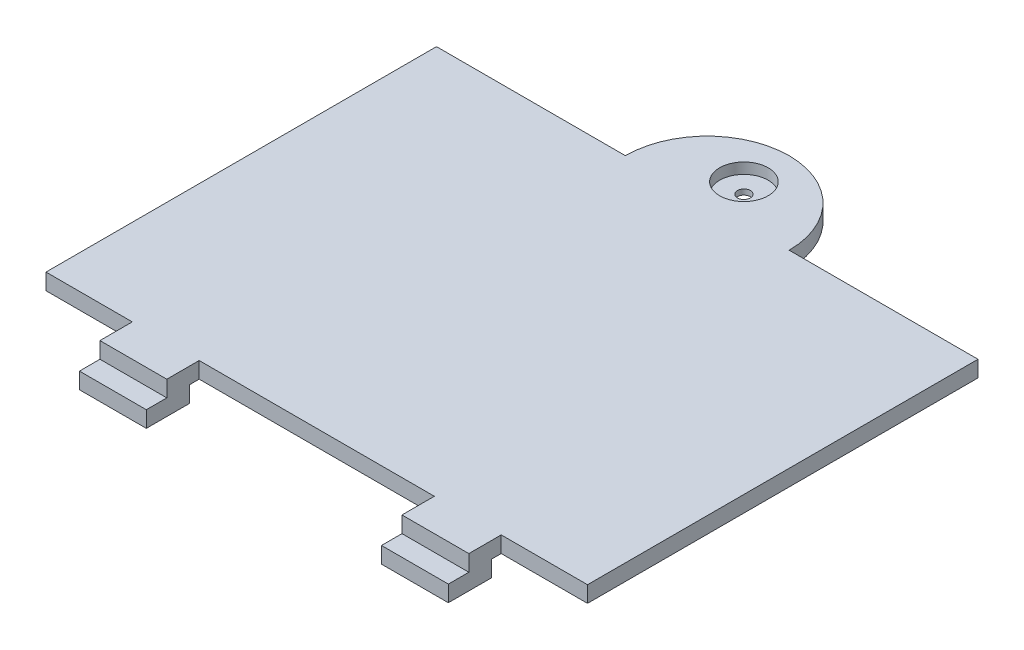
from build123d import *

# Parameters (mm, degrees)
SKETCH1_W           = 50.2
SKETCH1_H           = 36.2
BOSS_EXTRUDE1_DEPTH = 1.5
SKETCH2_W           = 6.2
SKETCH2_H           = 1.5
BOSS_EXTRUDE2_DEPTH = 3
BOSS_EXTRUDE3_DEPTH = 1.5
SKETCH5_R           = 2.25
CUT_EXTRUDE1_DEPTH  = 1
SKETCH6_R           = 0.6
CUT_EXTRUDE2_DEPTH  = 1
SKETCH9_W           = 6.2
SKETCH9_H           = 4
BOSS_EXTRUDE4_DEPTH = 1.5


with BuildPart() as part:
    # Sketch1 → Boss-Extrude1 (new body)
    with BuildSketch(Plane(origin=(0, 0, 0), x_dir=(1, 0, 0), z_dir=(0, 1, 0))):
        with Locations((-25.1, -18.1)):
            Rectangle(SKETCH1_W, SKETCH1_H)
    extrude(amount=BOSS_EXTRUDE1_DEPTH)

    # Sketch2 → Boss-Extrude2 (add)
    with BuildSketch(Plane.XY.offset(36.2)):
        with Locations((-39.1, 0.75)):
            Rectangle(SKETCH2_W, SKETCH2_H)
        with Locations((-11.1, 0.75)):
            Rectangle(SKETCH2_W, SKETCH2_H)
    extrude(amount=BOSS_EXTRUDE2_DEPTH)

    # Sketch4 → Boss-Extrude3 (add)
    with BuildSketch(Plane(origin=(0, 1.5, 0), x_dir=(1, 0, 0), z_dir=(0, 1, 0))):
        with BuildLine():
            Line((-32.69, 0), (-17.51, 0))
            ThreePointArc((-17.51, 0), (-25.1, 7.59), (-32.69, 0))
        make_face()
    extrude(amount=-BOSS_EXTRUDE3_DEPTH)

    # Sketch5 → Cut-Extrude1 (cut)
    with BuildSketch(Plane(origin=(0, 1.5, 0), x_dir=(1, 0, 0), z_dir=(0, 1, 0))):
        with Locations((-25.1, 3.4)):
            Circle(SKETCH5_R)
    extrude(amount=-CUT_EXTRUDE1_DEPTH, mode=Mode.SUBTRACT)

    # Sketch6 → Cut-Extrude2 (cut)
    with BuildSketch(Plane(origin=(0, 0.5, 0), x_dir=(1, 0, 0), z_dir=(0, 1, 0))):
        with Locations((-25.1, 3.4)):
            Circle(SKETCH6_R)
    extrude(amount=-CUT_EXTRUDE2_DEPTH, mode=Mode.SUBTRACT)

    # Sketch9 → Boss-Extrude4 (add)
    with BuildSketch(Plane.XZ):
        with Locations((-39.1, 39.1)):
            Rectangle(SKETCH9_W, SKETCH9_H)
        with Locations((-11.1, 39.1)):
            Rectangle(SKETCH9_W, SKETCH9_H)
    extrude(amount=BOSS_EXTRUDE4_DEPTH)


solid = part.part
